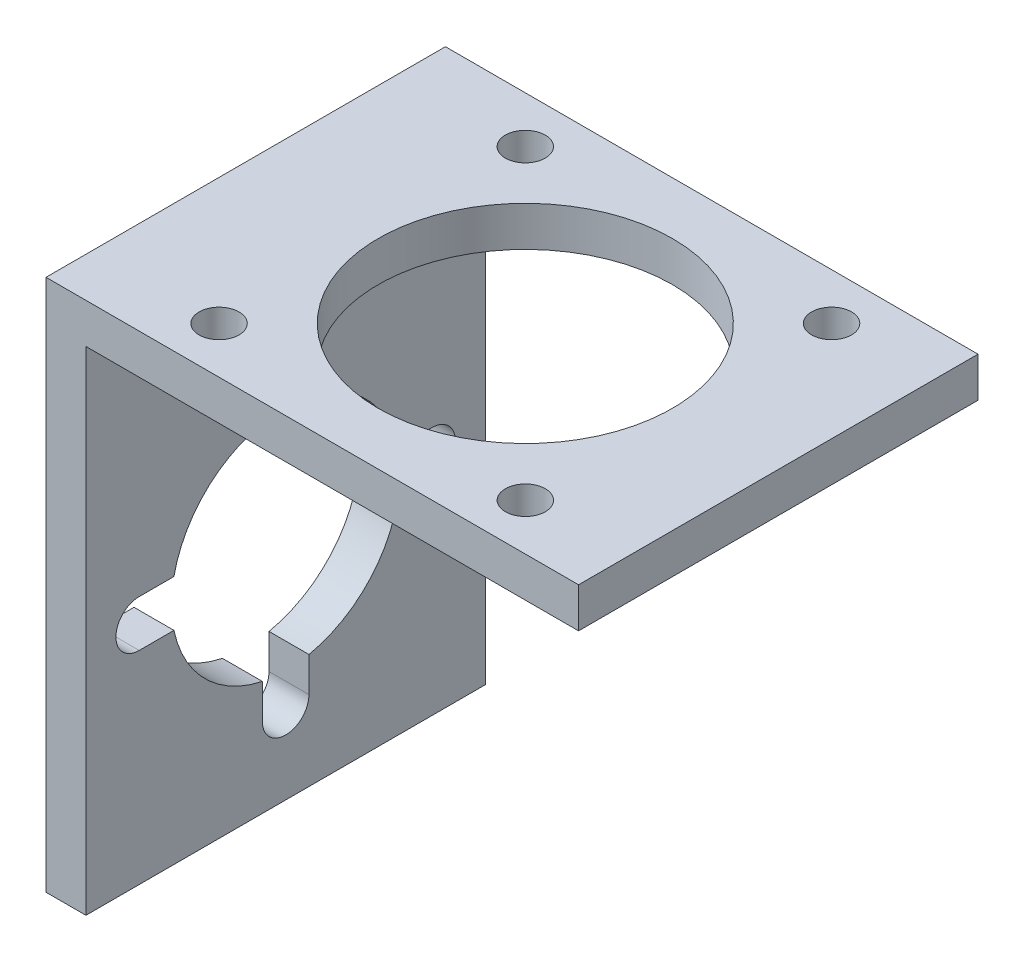
from build123d import *

# Parameters (mm, degrees)
BOSS_EXTRUDE1_DEPTH = 30
SKETCH2_R           = 11.05
SKETCH2_R_2         = 1.5
CUT_EXTRUDE1_DEPTH  = 4
CUT_EXTRUDE2_DEPTH  = 4


with BuildPart() as part:
    # Sketch1 → Boss-Extrude1 (new body)
    with BuildSketch(Plane.XY):
        Polygon((0, 0), (40, 0), (40, -3), (3, -3), (3, -40), (0, -40), (0, -3), align=None)
    extrude(amount=BOSS_EXTRUDE1_DEPTH)

    # Sketch2 → Cut-Extrude1 (cut, through all)
    with BuildSketch(Plane.XZ.offset(3)):
        with Locations((21, 15)):
            Circle(SKETCH2_R)
        with Locations((32.502183488, 26.5)):
            Circle(SKETCH2_R_2)
        with Locations((32.5, 3.497816512)):
            Circle(SKETCH2_R_2)
        with Locations((9.497816512, 3.5)):
            Circle(SKETCH2_R_2)
        with Locations((9.5, 26.502183488)):
            Circle(SKETCH2_R_2)
    extrude(amount=-CUT_EXTRUDE1_DEPTH, mode=Mode.SUBTRACT)

    # Sketch3 → Cut-Extrude2 (cut, through all)
    with BuildSketch(Plane(origin=(3, 0, 0), x_dir=(0, 0, -1), z_dir=(1, 0, 0))):
        with BuildLine():
            Line((-26, -21.27), (-23.389421911, -21.27))
            ThreePointArc((-23.389421911, -21.27), (-21.059905115, -16.960094885), (-16.75, -14.630578089))
            Line((-16.75, -14.630578089), (-16.75, -12.02))
            ThreePointArc((-16.75, -12.02), (-15, -10.27), (-13.25, -12.02))
            Line((-13.25, -12.02), (-13.25, -14.630578089))
            ThreePointArc((-13.25, -14.630578089), (-8.940094885, -16.960094885), (-6.610578089, -21.27))
            Line((-6.610578089, -21.27), (-4, -21.27))
            ThreePointArc((-4, -21.27), (-2.25, -23.02), (-4, -24.77))
            Line((-4, -24.77), (-6.610578089, -24.77))
            ThreePointArc((-6.610578089, -24.77), (-8.940094885, -29.079905115), (-13.25, -31.409421911))
            Line((-13.25, -31.409421911), (-13.25, -34.02))
            ThreePointArc((-13.25, -34.02), (-15, -35.77), (-16.75, -34.02))
            Line((-16.75, -34.02), (-16.75, -31.409421911))
            ThreePointArc((-16.75, -31.409421911), (-21.059905115, -29.079905115), (-23.389421911, -24.77))
            Line((-23.389421911, -24.77), (-26, -24.77))
            ThreePointArc((-26, -24.77), (-27.75, -23.02), (-26, -21.27))
        make_face()
    extrude(amount=-CUT_EXTRUDE2_DEPTH, mode=Mode.SUBTRACT)


solid = part.part
